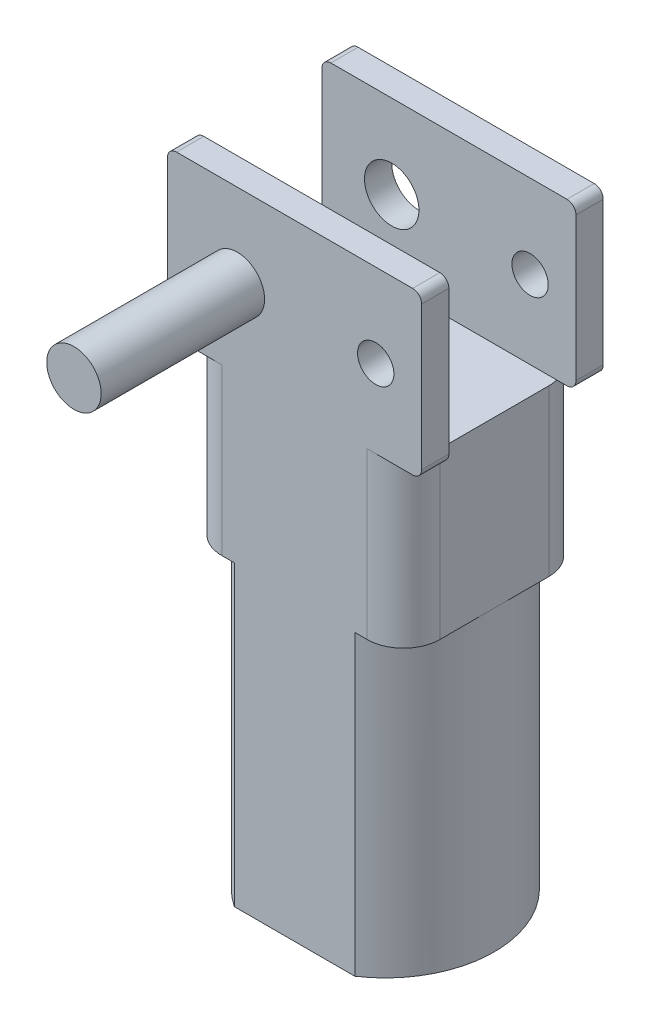
from build123d import *

# Parameters (mm, degrees)
BOSS_EXTRUDE1_DEPTH  = 16.4
SKETCH2_W            = 12
SKETCH2_H            = 10
BOSS_EXTRUDE2_DEPTH  = 9.1
FILLET1_R            = 2
SKETCH3_W            = 14
SKETCH3_H            = 8.9
SKETCH3_R            = 1.5
SKETCH3_R_2          = 1
BOSS_EXTRUDE3_DEPTH  = 1.5
FILLET2_R            = 0.5
FILLET2_OF_MIRROR1_R = 0.5
SKETCH4_R            = 1.5
BOSS_EXTRUDE4_DEPTH  = 9


with BuildPart() as part:
    # Sketch1 → Boss-Extrude1 (new body)
    with BuildSketch(Plane(origin=(0, 0, 0), x_dir=(1, 0, 0), z_dir=(0, 1, 0))):
        with BuildLine():
            Line((-3.31662479, 5), (3.31662479, 5))
            ThreePointArc((3.31662479, 5), (6, 0), (3.31662479, -5))
            Line((3.31662479, -5), (-3.31662479, -5))
            ThreePointArc((-3.31662479, -5), (-6, 0), (-3.31662479, 5))
        make_face()
    extrude(amount=BOSS_EXTRUDE1_DEPTH)

    # Sketch2 → Boss-Extrude2 (add)
    with BuildSketch(Plane(origin=(0, 16.4, 0), x_dir=(1, 0, 0), z_dir=(0, 1, 0))):
        Rectangle(SKETCH2_W, SKETCH2_H)
    extrude(amount=BOSS_EXTRUDE2_DEPTH)

    # Fillet1
    fillet1_edges = [part.edges().sort_by_distance(p)[0] for p in [
        (-6, 20.95, -5),
        (-6, 20.95, 5),
        (6, 20.95, 5),
        (6, 20.95, -5),
    ]]
    fillet(fillet1_edges, radius=FILLET1_R)

    # Sketch3 → Boss-Extrude3 (add)
    with BuildSketch(Plane.XY.offset(5)):
        with Locations((0, 29.95)):
            Rectangle(SKETCH3_W, SKETCH3_H)
        with Locations((-3.15, 29.8)):
            Circle(SKETCH3_R, mode=Mode.SUBTRACT)
        with Locations((4.47, 29.8)):
            Circle(SKETCH3_R_2, mode=Mode.SUBTRACT)
    boss_extrude3 = extrude(amount=-BOSS_EXTRUDE3_DEPTH)

    # Fillet2
    fillet2_edges = [part.edges().sort_by_distance(p)[0] for p in [
        (-7, 25.5, 4.25),
        (-7, 34.4, 4.25),
        (7, 34.4, 4.25),
        (7, 25.5, 4.25),
    ]]
    fillet(fillet2_edges, radius=FILLET2_R)

    # Mirror1: Boss-Extrude3 across plane
    add(boss_extrude3.mirror(Plane.XY))

    # Fillet2 of Mirror1
    fillet2_of_mirror1_edges = [part.edges().sort_by_distance(p)[0] for p in [
        (-7, 25.5, -4.25),
        (-7, 34.4, -4.25),
        (7, 34.4, -4.25),
        (7, 25.5, -4.25),
    ]]
    fillet(fillet2_of_mirror1_edges, radius=FILLET2_OF_MIRROR1_R)


with BuildPart() as body_2:
    # Sketch4 → Boss-Extrude4 (new body)
    with BuildSketch(Plane.XY.offset(5)):
        with Locations((-3.15, 29.8)):
            Circle(SKETCH4_R)
    extrude(amount=BOSS_EXTRUDE4_DEPTH)


solid = Compound([part.part, body_2.part])
